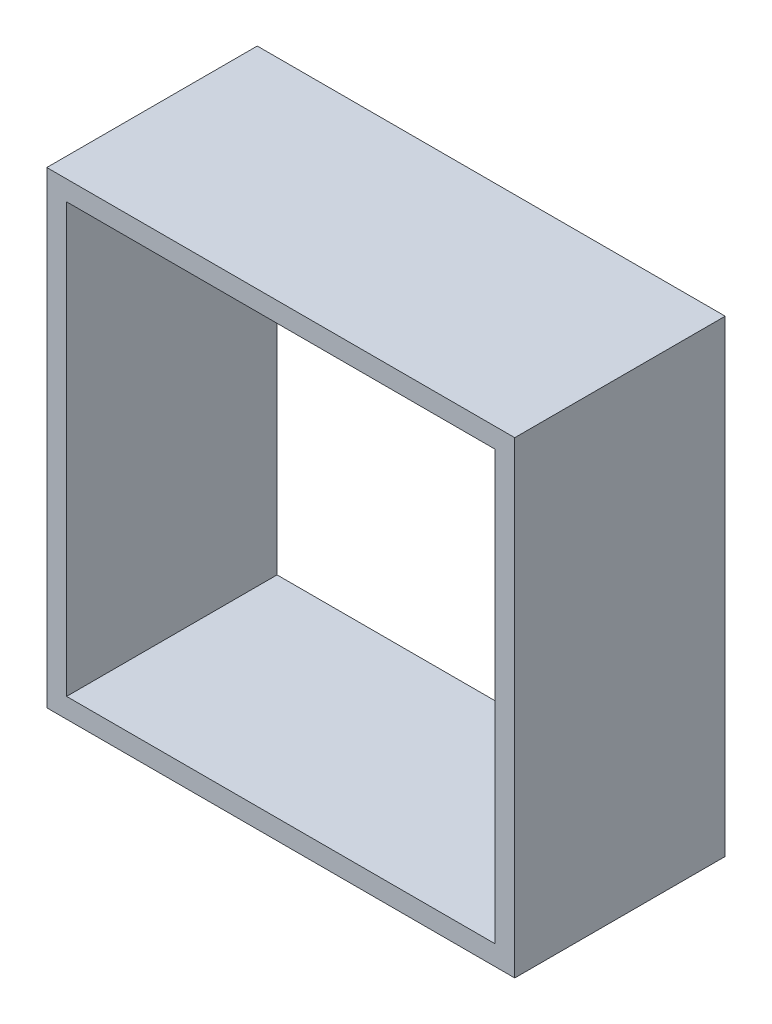
from build123d import *

# Parameters (mm, degrees)
SKETCH1_W           = 18.9
SKETCH1_H           = 18.9
SKETCH1_W_2         = 17.3
SKETCH1_H_2         = 17.3
BOSS_EXTRUDE1_DEPTH = 8.5


with BuildPart() as part:
    # Sketch1 → Boss-Extrude1 (new body)
    with BuildSketch(Plane.XY):
        Rectangle(SKETCH1_W, SKETCH1_H)
        Rectangle(SKETCH1_W_2, SKETCH1_H_2, mode=Mode.SUBTRACT)
    extrude(amount=BOSS_EXTRUDE1_DEPTH)


solid = part.part
